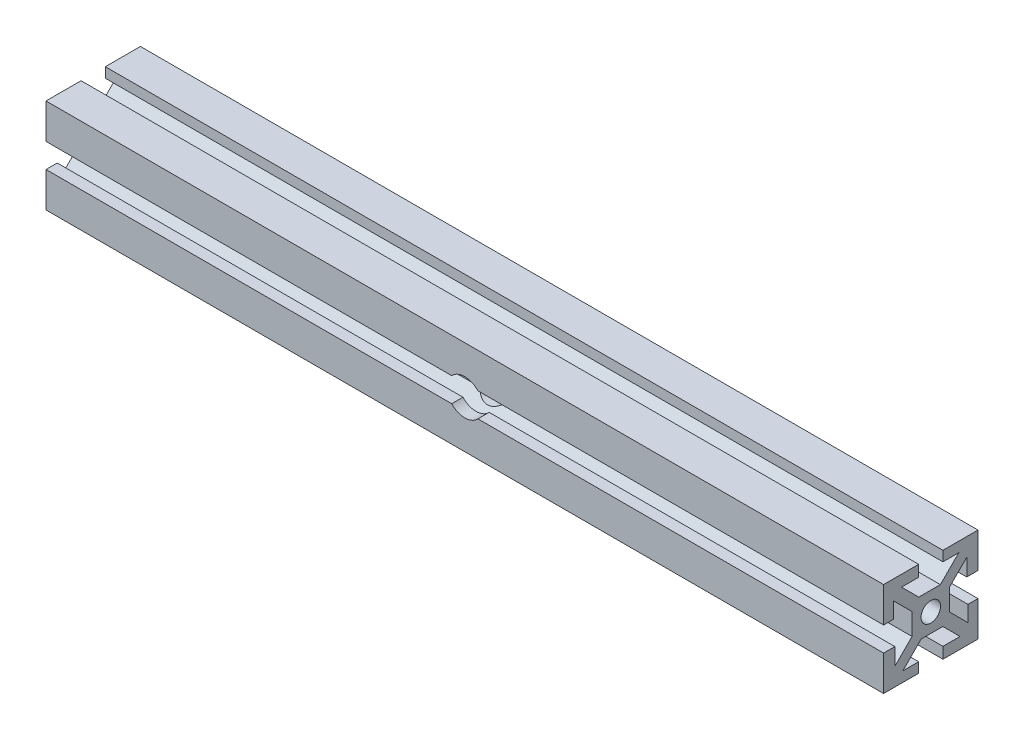
from build123d import *

# Parameters (mm, degrees)
SKETCH1_R               = 2.605
BOSS_EXTRUDE1_DEPTH     = 223.52
CIRPATTERN1_COUNT       = 4
CUT_EXTRUDE2_DEPTH      = 10
CUT_EXTRUDE2_DEPTH_BACK = 50
SKETCH2_R               = 4.765


with BuildPart() as part:
    # Sketch1 → Boss-Extrude1 (new body)
    with BuildSketch(Plane(origin=(0, 0, 0), x_dir=(0, 0, -1), z_dir=(1, 0, 0))):
        Polygon((5, -5), (5, 3.203948776), (9.596194078, 7.800142853), (9.596194078, 3.24), (12.596194078, 3.24), (12.596194078, 12.596194078), (3.24, 12.596194078), (3.24, 9.921463197), (7.474873734, 9.921463197), (2.553410537, 5), (-5, 5), (-5, -5), align=None)
        Circle(SKETCH1_R, mode=Mode.SUBTRACT)
    boss_extrude1 = extrude(amount=BOSS_EXTRUDE1_DEPTH)

    # CirPattern1: Boss-Extrude1 ×4 about axis
    cirpattern1_axis = Axis((0, 0, 0), (1, 0, 0))
    for i in range(1, CIRPATTERN1_COUNT):
        add(boss_extrude1.rotate(cirpattern1_axis, i * 360 / CIRPATTERN1_COUNT))

    # Sketch2 → Cut-Extrude2 (cut, two sides: drawn at the far end of the back side and taken through both)
    with BuildSketch(Plane.XY.offset(12.596194078).offset(-CUT_EXTRUDE2_DEPTH_BACK)):
        with Locations((111.76, 0)):
            Circle(SKETCH2_R)
    extrude(amount=CUT_EXTRUDE2_DEPTH + CUT_EXTRUDE2_DEPTH_BACK, mode=Mode.SUBTRACT)


solid = part.part
